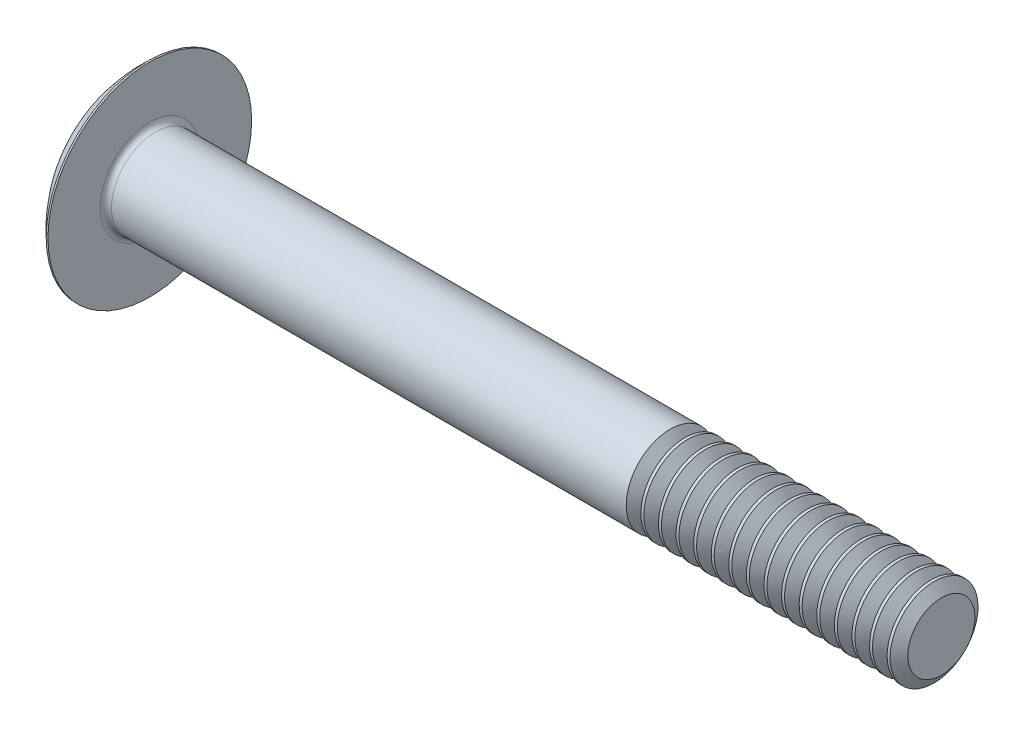
from build123d import *

# Parameters (mm, degrees)
THDSCHPAT_COUNT = 16
THDSCHPAT_PITCH = 1.27


with BuildPart() as part:
    # BodySke → Base-Revolve (revolve)
    with BuildSketch(Plane.XY):
        with BuildLine():
            Line((0, 0), (60.579, 0))
            Line((60.579, 0), (60.579, 3.175))
            Line((60.579, 3.175), (3.8354, 3.175))
            ThreePointArc((3.8354, 3.175), (3.548031804, 3.294031804), (3.429, 3.5814))
            Line((3.429, 3.5814), (3.429, 7.3533))
            Line((3.429, 7.3533), (3.302, 7.3533))
            ThreePointArc((3.302, 7.3533), (0.863382865, 4.030329543), (0, 0))
        make_face()
    revolve(axis=Axis((0, 0, 0), (1, 0, 0)))

    # ThdSchSke → ThreadSchematic (revolve, cut)
    with BuildSketch(Plane.XY):
        Polygon((41.529, -2.41935), (40.999888174, -3.175), (40.999888174, -3.96875), (42.058111826, -3.96875), (42.058111826, -3.175), align=None)
    threadschematic = revolve(axis=Axis((-3.175, 0, 0), (1, 0, 0)), mode=Mode.SUBTRACT)

    # ThdSchPat: ThreadSchematic ×16
    with Locations(*[(i * THDSCHPAT_PITCH, 0, 0) for i in range(1, THDSCHPAT_COUNT)]):
        add(threadschematic, mode=Mode.SUBTRACT)


solid = part.part
